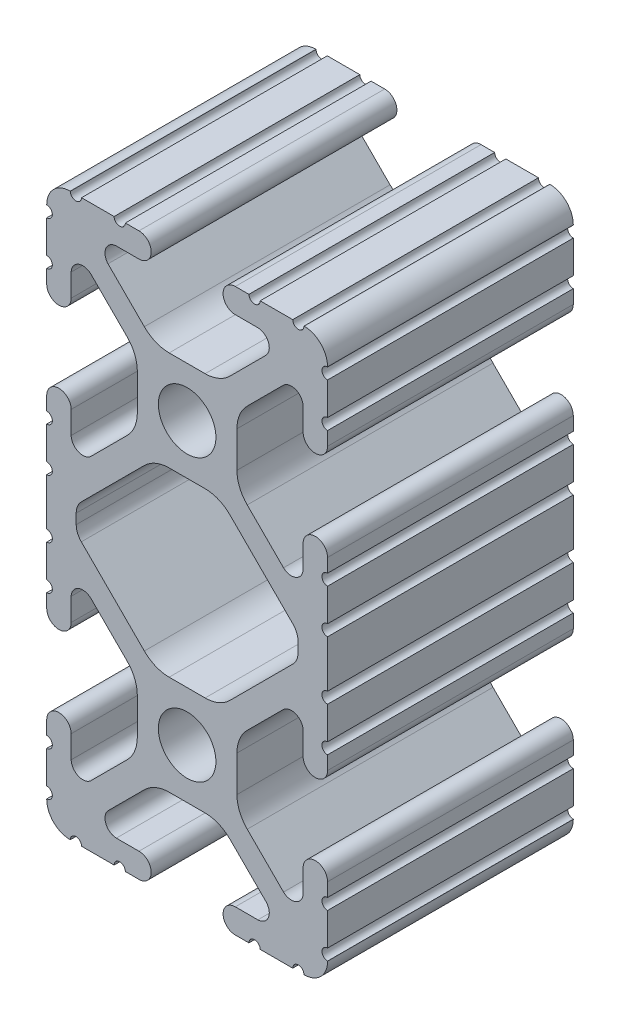
from build123d import *

# Parameters (mm, degrees)
SKETCH1_R      = 2.6035
EXTRUDE1_DEPTH = 22.225


with BuildPart() as part:
    # Sketch1 → Extrude1 (new body)
    with BuildSketch(Plane.XY):
        with BuildLine():
            Line((925.030031307, 602.850527299), (925.030031307, 605.796927299))
            ThreePointArc((925.030031307, 605.796927299), (924.522031307, 606.304927299), (925.030031307, 606.812927299))
            Line((925.030031307, 606.812927299), (925.030031307, 608.044827299))
            ThreePointArc((925.030031307, 608.044827299), (923.925131307, 609.149727299), (922.820231307, 608.044827299))
            Line((922.820231307, 608.044827299), (922.820231307, 605.99597822))
            ThreePointArc((922.820231307, 605.99597822), (922.173798087, 605.055266469), (921.048395335, 605.245747838))
            Line((921.048395335, 605.245747838), (917.764377722, 608.529666789))
            ThreePointArc((917.764377722, 608.529666789), (917.076099637, 609.559722614), (916.834408027, 610.774764544))
            Line((916.834408027, 610.774764544), (916.834408027, 614.027171862))
            ThreePointArc((916.834408027, 614.027171862), (917.076098205, 615.242210334), (917.764372429, 616.272264325))
            Line((917.764372429, 616.272264325), (921.048175959, 619.555984679))
            ThreePointArc((921.048175959, 619.555984679), (922.176497414, 619.74525718), (922.820231307, 618.799455901))
            Line((922.820231307, 618.799455901), (922.820231307, 616.757027299))
            ThreePointArc((922.820231307, 616.757027299), (923.925131307, 615.652127299), (925.030031307, 616.757027299))
            Line((925.030031307, 616.757027299), (925.030031307, 617.988927299))
            ThreePointArc((925.030031307, 617.988927299), (924.522031307, 618.496927299), (925.030031307, 619.004927299))
            Line((925.030031307, 619.004927299), (925.030031307, 621.951327299))
            ThreePointArc((925.030031307, 621.951327299), (924.522031307, 622.459327299), (925.030031307, 622.967327299))
            Line((925.030031307, 622.967327299), (925.030031307, 622.992727299))
            ThreePointArc((925.030031307, 622.992727299), (924.412553823, 624.483449815), (922.921831307, 625.100927299))
            Line((922.921831307, 625.100927299), (922.896431307, 625.100927299))
            ThreePointArc((922.896431307, 625.100927299), (922.388431307, 624.592927299), (921.880431307, 625.100927299))
            Line((921.880431307, 625.100927299), (918.934031307, 625.100927299))
            ThreePointArc((918.934031307, 625.100927299), (918.426031307, 624.592927299), (917.918031307, 625.100927299))
            Line((917.918031307, 625.100927299), (916.686131307, 625.100927299))
            ThreePointArc((916.686131307, 625.100927299), (915.581231307, 623.996027299), (916.686131307, 622.891127299))
            Line((916.686131307, 622.891127299), (918.734980386, 622.891127299))
            ThreePointArc((918.734980386, 622.891127299), (919.675692137, 622.244694079), (919.485210768, 621.119291326))
            Line((919.485210768, 621.119291326), (916.201291817, 617.835273713))
            ThreePointArc((916.201291817, 617.835273713), (915.171235992, 617.146995629), (913.956194062, 616.905304018))
            Line((913.956194062, 616.905304018), (910.703786744, 616.905304018))
            ThreePointArc((910.703786744, 616.905304018), (909.488748272, 617.146994197), (908.458694281, 617.835268421))
            Line((908.458694281, 617.835268421), (905.174973927, 621.11907195))
            ThreePointArc((905.174973927, 621.11907195), (904.985701426, 622.247393405), (905.931502705, 622.891127299))
            Line((905.931502705, 622.891127299), (907.973931307, 622.891127299))
            ThreePointArc((907.973931307, 622.891127299), (909.078831307, 623.996027299), (907.973931307, 625.100927299))
            Line((907.973931307, 625.100927299), (906.742031307, 625.100927299))
            ThreePointArc((906.742031307, 625.100927299), (906.234031307, 624.592927299), (905.726031307, 625.100927299))
            Line((905.726031307, 625.100927299), (902.779631307, 625.100927299))
            ThreePointArc((902.779631307, 625.100927299), (902.271631307, 624.592927299), (901.763631307, 625.100927299))
            Line((901.763631307, 625.100927299), (901.738231307, 625.100927299))
            ThreePointArc((901.738231307, 625.100927299), (900.247508791, 624.483449815), (899.630031307, 622.992727299))
            Line((899.630031307, 622.992727299), (899.630031307, 622.967327299))
            ThreePointArc((899.630031307, 622.967327299), (900.138031307, 622.459327299), (899.630031307, 621.951327299))
            Line((899.630031307, 621.951327299), (899.630031307, 619.004927299))
            ThreePointArc((899.630031307, 619.004927299), (900.138031307, 618.496927299), (899.630031307, 617.988927299))
            Line((899.630031307, 617.988927299), (899.630031307, 616.757027299))
            ThreePointArc((899.630031307, 616.757027299), (900.734931307, 615.652127299), (901.839831307, 616.757027299))
            Line((901.839831307, 616.757027299), (901.839831307, 618.805876378))
            ThreePointArc((901.839831307, 618.805876378), (902.486264527, 619.746588129), (903.61166728, 619.55610676))
            Line((903.61166728, 619.55610676), (906.895684893, 616.272187809))
            ThreePointArc((906.895684893, 616.272187809), (907.583962977, 615.242131983), (907.825654588, 614.027090054))
            Line((907.825654588, 614.027090054), (907.825654588, 610.774682736))
            ThreePointArc((907.825654588, 610.774682736), (907.583964409, 609.559644263), (906.895690185, 608.529590273))
            Line((906.895690185, 608.529590273), (903.611886656, 605.245869918))
            ThreePointArc((903.611886656, 605.245869918), (902.483565201, 605.056597418), (901.839831307, 606.002398697))
            Line((901.839831307, 606.002398697), (901.839831307, 608.044827299))
            ThreePointArc((901.839831307, 608.044827299), (900.734931307, 609.149727299), (899.630031307, 608.044827299))
            Line((899.630031307, 608.044827299), (899.630031307, 606.812927299))
            ThreePointArc((899.630031307, 606.812927299), (900.138031307, 606.304927299), (899.630031307, 605.796927299))
            Line((899.630031307, 605.796927299), (899.630031307, 602.850527299))
            ThreePointArc((899.630031307, 602.850527299), (900.138031307, 602.342527299), (899.630031307, 601.834527299))
            Line((899.630031307, 601.834527299), (899.630031307, 597.567327299))
            ThreePointArc((899.630031307, 597.567327299), (900.138031307, 597.059327299), (899.630031307, 596.551327299))
            Line((899.630031307, 596.551327299), (899.630031307, 593.604927299))
            ThreePointArc((899.630031307, 593.604927299), (900.138031307, 593.096927299), (899.630031307, 592.588927299))
            Line((899.630031307, 592.588927299), (899.630031307, 591.357027299))
            ThreePointArc((899.630031307, 591.357027299), (900.734931307, 590.252127299), (901.839831307, 591.357027299))
            Line((901.839831307, 591.357027299), (901.839831307, 593.405876378))
            ThreePointArc((901.839831307, 593.405876378), (902.486264527, 594.346588129), (903.61166728, 594.15610676))
            Line((903.61166728, 594.15610676), (906.895684893, 590.872187809))
            ThreePointArc((906.895684893, 590.872187809), (907.583962977, 589.842131983), (907.825654588, 588.627090054))
            Line((907.825654588, 588.627090054), (907.825654588, 585.374682736))
            ThreePointArc((907.825654588, 585.374682736), (907.583964409, 584.159644263), (906.895690185, 583.129590273))
            Line((906.895690185, 583.129590273), (903.611886656, 579.845869918))
            ThreePointArc((903.611886656, 579.845869918), (902.483565201, 579.656597418), (901.839831307, 580.602398697))
            Line((901.839831307, 580.602398697), (901.839831307, 582.644827299))
            ThreePointArc((901.839831307, 582.644827299), (900.734931307, 583.749727299), (899.630031307, 582.644827299))
            Line((899.630031307, 582.644827299), (899.630031307, 581.412927299))
            ThreePointArc((899.630031307, 581.412927299), (900.138031307, 580.904927299), (899.630031307, 580.396927299))
            Line((899.630031307, 580.396927299), (899.630031307, 577.450527299))
            ThreePointArc((899.630031307, 577.450527299), (900.138031307, 576.942527299), (899.630031307, 576.434527299))
            Line((899.630031307, 576.434527299), (899.630031307, 576.409127299))
            ThreePointArc((899.630031307, 576.409127299), (900.247508791, 574.918404783), (901.738231307, 574.300927299))
            Line((901.738231307, 574.300927299), (901.763631307, 574.300927299))
            ThreePointArc((901.763631307, 574.300927299), (902.271631307, 574.808927299), (902.779631307, 574.300927299))
            Line((902.779631307, 574.300927299), (905.726031307, 574.300927299))
            ThreePointArc((905.726031307, 574.300927299), (906.234031307, 574.808927299), (906.742031307, 574.300927299))
            Line((906.742031307, 574.300927299), (907.973931307, 574.300927299))
            ThreePointArc((907.973931307, 574.300927299), (909.078831307, 575.405827299), (907.973931307, 576.510727299))
            Line((907.973931307, 576.510727299), (905.925082228, 576.510727299))
            ThreePointArc((905.925082228, 576.510727299), (904.984370477, 577.157160519), (905.174851846, 578.282563271))
            Line((905.174851846, 578.282563271), (908.458770797, 581.566580884))
            ThreePointArc((908.458770797, 581.566580884), (909.488826623, 582.254858969), (910.703868552, 582.496550579))
            Line((910.703868552, 582.496550579), (913.95627587, 582.496550579))
            ThreePointArc((913.95627587, 582.496550579), (915.171314343, 582.254860401), (916.201368333, 581.566586177))
            Line((916.201368333, 581.566586177), (919.485088688, 578.282782647))
            ThreePointArc((919.485088688, 578.282782647), (919.674361188, 577.154461192), (918.728559909, 576.510727299))
            Line((918.728559909, 576.510727299), (916.686131307, 576.510727299))
            ThreePointArc((916.686131307, 576.510727299), (915.581231307, 575.405827299), (916.686131307, 574.300927299))
            Line((916.686131307, 574.300927299), (917.918031307, 574.300927299))
            ThreePointArc((917.918031307, 574.300927299), (918.426031307, 574.808927299), (918.934031307, 574.300927299))
            Line((918.934031307, 574.300927299), (921.880431307, 574.300927299))
            ThreePointArc((921.880431307, 574.300927299), (922.388431307, 574.808927299), (922.896431307, 574.300927299))
            Line((922.896431307, 574.300927299), (922.921831307, 574.300927299))
            ThreePointArc((922.921831307, 574.300927299), (924.412553823, 574.918404783), (925.030031307, 576.409127299))
            Line((925.030031307, 576.409127299), (925.030031307, 576.434527299))
            ThreePointArc((925.030031307, 576.434527299), (924.522031307, 576.942527299), (925.030031307, 577.450527299))
            Line((925.030031307, 577.450527299), (925.030031307, 580.396927299))
            ThreePointArc((925.030031307, 580.396927299), (924.522031307, 580.904927299), (925.030031307, 581.412927299))
            Line((925.030031307, 581.412927299), (925.030031307, 582.644827299))
            ThreePointArc((925.030031307, 582.644827299), (923.925131307, 583.749727299), (922.820231307, 582.644827299))
            Line((922.820231307, 582.644827299), (922.820231307, 580.59597822))
            ThreePointArc((922.820231307, 580.59597822), (922.173798087, 579.655266469), (921.048395335, 579.845747838))
            Line((921.048395335, 579.845747838), (917.764377722, 583.129666789))
            ThreePointArc((917.764377722, 583.129666789), (917.076099637, 584.159722614), (916.834408027, 585.374764544))
            Line((916.834408027, 585.374764544), (916.834408027, 588.627171862))
            ThreePointArc((916.834408027, 588.627171862), (917.076098205, 589.842210334), (917.764372429, 590.872264325))
            Line((917.764372429, 590.872264325), (921.048175959, 594.155984679))
            ThreePointArc((921.048175959, 594.155984679), (922.176497414, 594.34525718), (922.820231307, 593.399455901))
            Line((922.820231307, 593.399455901), (922.820231307, 591.357027299))
            ThreePointArc((922.820231307, 591.357027299), (923.925131307, 590.252127299), (925.030031307, 591.357027299))
            Line((925.030031307, 591.357027299), (925.030031307, 592.588927299))
            ThreePointArc((925.030031307, 592.588927299), (924.522031307, 593.096927299), (925.030031307, 593.604927299))
            Line((925.030031307, 593.604927299), (925.030031307, 596.551327299))
            ThreePointArc((925.030031307, 596.551327299), (924.522031307, 597.059327299), (925.030031307, 597.567327299))
            Line((925.030031307, 597.567327299), (925.030031307, 601.834527299))
            ThreePointArc((925.030031307, 601.834527299), (924.522031307, 602.342527299), (925.030031307, 602.850527299))
        make_face()
        with Locations((912.330031307, 612.400927299)):
            Circle(SKETCH1_R, mode=Mode.SUBTRACT)
        with Locations((912.330031307, 587.000927299)):
            Circle(SKETCH1_R, mode=Mode.SUBTRACT)
        with BuildLine():
            Line((902.297031307, 599.249379301), (902.297031307, 600.152366611))
            ThreePointArc((902.297031307, 600.152366611), (902.416901293, 600.755005552), (902.758262821, 601.265901642))
            Line((902.758262821, 601.265901642), (908.458770797, 606.966580884))
            ThreePointArc((908.458770797, 606.966580884), (909.488826623, 607.654858969), (910.703868552, 607.896550579))
            Line((910.703868552, 607.896550579), (913.95627587, 607.896550579))
            ThreePointArc((913.95627587, 607.896550579), (915.171314343, 607.654860401), (916.201368333, 606.966586177))
            Line((916.201368333, 606.966586177), (921.901797169, 601.266012953))
            ThreePointArc((921.901797169, 601.266012953), (922.243160611, 600.755115953), (922.363031307, 600.152475296))
            Line((922.363031307, 600.152475296), (922.363031307, 599.249487987))
            ThreePointArc((922.363031307, 599.249487987), (922.243161321, 598.646849046), (921.901799794, 598.135952956))
            Line((921.901799794, 598.135952956), (916.201291817, 592.435273713))
            ThreePointArc((916.201291817, 592.435273713), (915.171235992, 591.746995629), (913.956194062, 591.505304018))
            Line((913.956194062, 591.505304018), (910.703786744, 591.505304018))
            ThreePointArc((910.703786744, 591.505304018), (909.488748272, 591.746994197), (908.458694281, 592.435268421))
            Line((908.458694281, 592.435268421), (902.758265446, 598.135841645))
            ThreePointArc((902.758265446, 598.135841645), (902.416902003, 598.646738645), (902.297031307, 599.249379301))
        make_face(mode=Mode.SUBTRACT)
    extrude(amount=-EXTRUDE1_DEPTH)


solid = part.part
